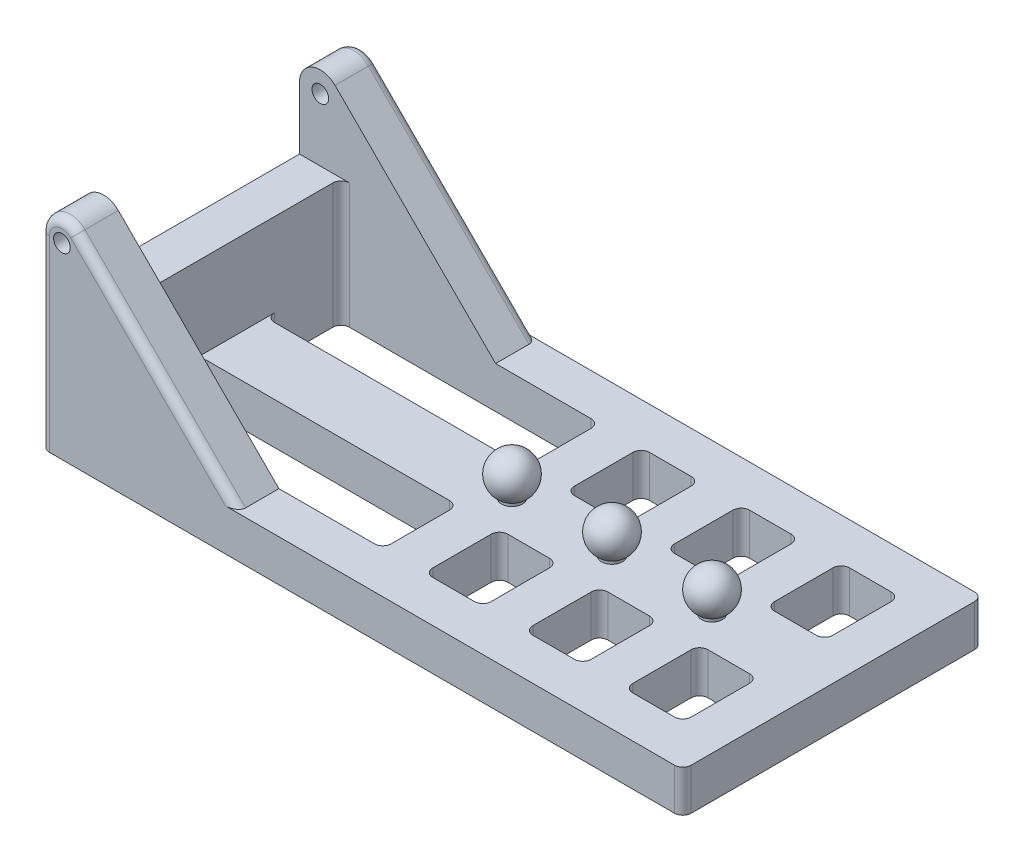
from build123d import *

# Parameters (mm, degrees)
SKETCH_1_W              = 770
SKETCH_1_H              = 360
SKETCH_1_W_2            = 670
SKETCH_1_H_2            = 260
EXTRUDE_1_DEPTH         = 50
SKETCH_2_R              = 10
EXTRUDE_2_DEPTH         = 50
SKETCH_3_R              = 10
EXTRUDE_3_DEPTH         = 50
SKETCH_4_W              = 670
SKETCH_4_H              = 80
EXTRUDE_4_DEPTH         = 50
SKETCH_8_W              = 50
SKETCH_8_H              = 260
EXTRUDE_6_DEPTH         = 100
PATTERN_LINEAR_27_COUNT = 3
PATTERN_LINEAR_27_PITCH = 120
SKETCH_12_W             = 50
SKETCH_12_H             = 260
EXTRUDE_10_DEPTH        = 50
FILLET_3_R              = 10


with BuildPart() as part:
    # 草图1 → 凸台-拉伸1 (new body)
    with BuildSketch(Plane(origin=(0, 0, 0), x_dir=(1, 0, 0), z_dir=(0, 1, 0))):
        Rectangle(SKETCH_1_W, SKETCH_1_H)
        Rectangle(SKETCH_1_W_2, SKETCH_1_H_2, mode=Mode.SUBTRACT)
    extrude(amount=EXTRUDE_1_DEPTH)

    # 草图2 → 凸台-拉伸2 (add)
    with BuildSketch(Plane.XY.offset(180)):
        with BuildLine():
            Line((-385, 50), (-385, 225))
            ThreePointArc((-385, 225), (-369.567085809, 248.096988313), (-342.32233047, 242.67766953))
            Line((-342.32233047, 242.67766953), (-149.644660941, 50))
            Line((-149.644660941, 50), (-385, 50))
        make_face()
        with Locations((-360, 225)):
            Circle(SKETCH_2_R, mode=Mode.SUBTRACT)
    extrude(amount=-EXTRUDE_2_DEPTH)

    # 草图3 → 凸台-拉伸3 (add)
    with BuildSketch(Plane(origin=(0, 0, -180), x_dir=(-1, 0, 0), z_dir=(0, 0, -1))):
        with BuildLine():
            Line((149.644660941, 50), (385, 50))
            Line((385, 50), (385, 225))
            ThreePointArc((385, 225), (369.567085809, 248.096988313), (342.32233047, 242.67766953))
            Line((342.32233047, 242.67766953), (149.644660941, 50))
        make_face()
        with Locations((360, 225)):
            Circle(SKETCH_3_R, mode=Mode.SUBTRACT)
    extrude(amount=-EXTRUDE_3_DEPTH)

    # 草图4 → 凸台-拉伸4 (add)
    with BuildSketch(Plane(origin=(0, 50, 0), x_dir=(1, 0, 0), z_dir=(0, 1, 0))):
        Rectangle(SKETCH_4_W, SKETCH_4_H)
    extrude(amount=-EXTRUDE_4_DEPTH)

    # 草图8 → 凸台-拉伸6 (add)
    with BuildSketch(Plane(origin=(0, 50, 0), x_dir=(1, 0, 0), z_dir=(0, 1, 0))):
        with Locations((-360, 0)):
            Rectangle(SKETCH_8_W, SKETCH_8_H)
    extrude(amount=EXTRUDE_6_DEPTH)

    # 草图11 → 旋转1 (revolve)
    with BuildSketch(Plane.XY):
        with BuildLine():
            Line((0, 50), (12.5, 50))
            Line((12.5, 50), (12.5, 53.349364905))
            ThreePointArc((12.5, 53.349364905), (24.148145657, 81.470476128), (0, 100))
            Line((0, 100), (0, 99.72990561))
            Line((0, 99.72990561), (0, 50))
        make_face()
    revolve_1 = revolve(axis=Axis((0, 50, 0), (0, 1, 0)))

    # 阵列(线性)27: 旋转1 ×3
    with Locations(*[(i * PATTERN_LINEAR_27_PITCH, 0, 0) for i in range(1, PATTERN_LINEAR_27_COUNT)]):
        add(revolve_1)

    # 草图12 → 凸台-拉伸10 (add)
    with BuildSketch(Plane(origin=(0, 50, 0), x_dir=(1, 0, 0), z_dir=(0, 1, 0))):
        Rectangle(SKETCH_12_W, SKETCH_12_H)
        with Locations((120, 0)):
            Rectangle(SKETCH_12_W, SKETCH_12_H)
        with Locations((240, 0)):
            Rectangle(SKETCH_12_W, SKETCH_12_H)
    extrude(amount=-EXTRUDE_10_DEPTH)

    # 圆角3
    fillet_3_edges = [part.edges().sort_by_distance(p)[0] for p in [
        (-25, 25, 40),
        (25, 25, 40),
        (25, 25, -40),
        (25, 25, -130),
        (-25, 25, -40),
        (25, 25, 130),
        (-25, 25, 130),
        (-25, 25, -130),
        (145, 25, -40),
        (145, 25, -130),
        (95, 25, -40),
        (95, 25, -130),
        (145, 25, 40),
        (145, 25, 130),
        (95, 25, 40),
        (95, 25, 130),
        (-335, 75, 130),
        (335, 25, 130),
        (335, 25, -130),
        (-335, 75, -130),
        (265, 25, -40),
        (265, 25, -130),
        (215, 25, -40),
        (215, 25, -130),
        (265, 25, 40),
        (265, 25, 130),
        (215, 25, 40),
        (215, 25, 130),
        (-245.983495706, 146.338834765, 180),
        (-369.567085809, 248.096988313, 180),
        (-245.983495706, 146.338834765, -180),
        (-369.567085809, 248.096988313, -180),
        (-335, 25, 40),
        (-335, 25, -40),
        (335, 25, -40),
        (335, 25, 40),
        (-385, 112.5, -180),
        (385, 25, -180),
        (385, 25, 180),
        (-385, 112.5, 180),
    ]]
    fillet(fillet_3_edges, radius=FILLET_3_R)


solid = part.part
